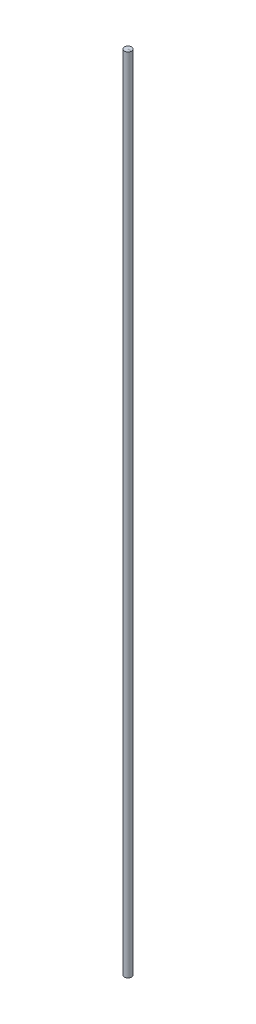
from build123d import *

# Parameters (mm, degrees)
SKETCH1_R           = 2
BOSS_EXTRUDE1_DEPTH = 440.000000112
BOSS_EXTRUDE2_DEPTH = 0.0254


with BuildPart() as part:
    # Sketch1 → Boss-Extrude1 (new body)
    with BuildSketch(Plane(origin=(0, 0, 0), x_dir=(1, 0, 0), z_dir=(0, 1, 0))):
        Circle(SKETCH1_R)
    extrude(amount=BOSS_EXTRUDE1_DEPTH)

    # Sketch2 → Boss-Extrude2 (add)
    with BuildSketch(Plane(origin=(0, 440.000000112, 0), x_dir=(1, 0, 0), z_dir=(0, 1, 0))):
        Polygon((0, 0), (2, 0), (0, -0.161399324), align=None)
    boss_extrude2 = extrude(amount=BOSS_EXTRUDE2_DEPTH)

    # Mirror1: Boss-Extrude2 across plane
    add(boss_extrude2.mirror(Plane.ZX.offset(220.000000056)))


solid = part.part
